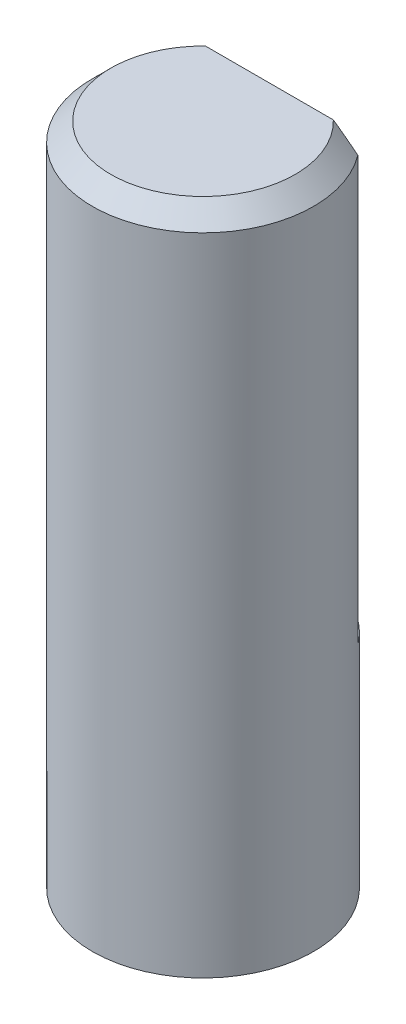
from build123d import *

# Parameters (mm, degrees)
SKETCH_1_R          = 3
EXTRUDE_1_DEPTH     = 18
CHAMFER_1_SIZE      = 0.5
CUT_EXTRUDE_1_DEPTH = 12


with BuildPart() as part:
    # Эскиз1 → Бобышка-Вытянуть1 (new body)
    with BuildSketch(Plane(origin=(0, 0, 0), x_dir=(1, 0, 0), z_dir=(0, 1, 0))):
        Circle(SKETCH_1_R)
    extrude(amount=EXTRUDE_1_DEPTH)

    # Фаска1
    chamfer_1_edges = [part.edges().sort_by_distance(p)[0] for p in [
        (-3, 18, 0),
    ]]
    chamfer(chamfer_1_edges, length=CHAMFER_1_SIZE)

    # Эскиз2 → Вырез-Вытянуть1 (cut)
    with BuildSketch(Plane(origin=(0, 18, 0), x_dir=(1, 0, 0), z_dir=(0, 1, 0))):
        with BuildLine():
            Line((-2.4, 1.8), (2.4, 1.8))
            ThreePointArc((2.4, 1.8), (0, 3), (-2.4, 1.8))
        make_face()
    extrude(amount=-CUT_EXTRUDE_1_DEPTH, mode=Mode.SUBTRACT)


solid = part.part
